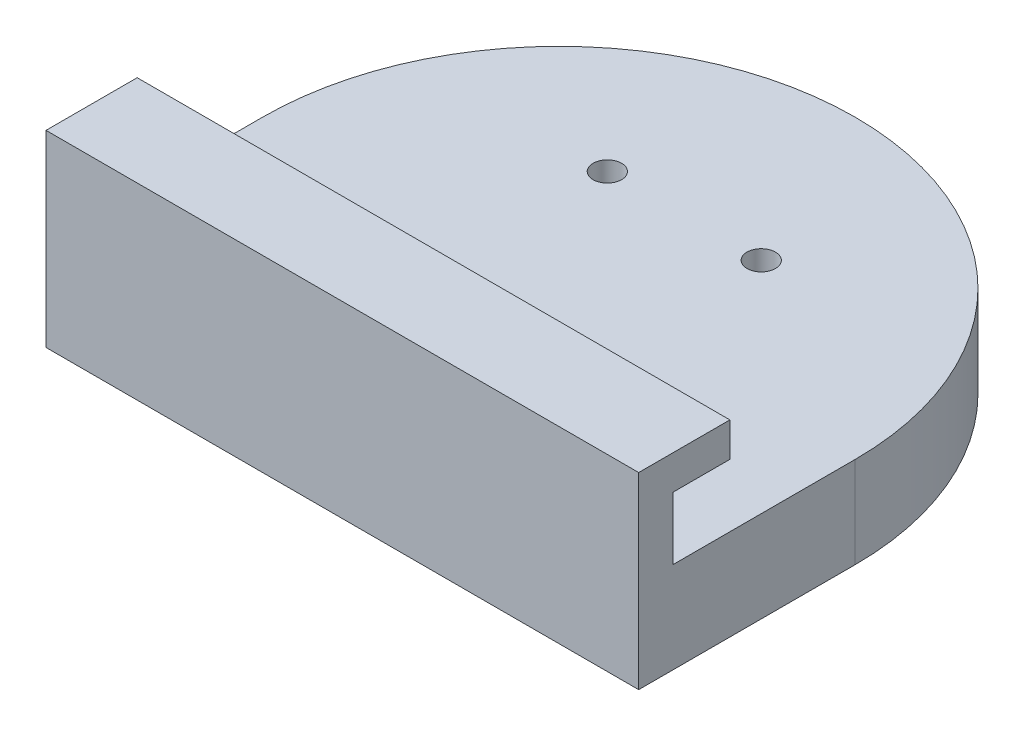
from build123d import *

# Parameters (mm, degrees)
BOSS_EXTRUDE1_DEPTH             = 2
BOSS_EXTRUDE3_DEPTH             = 8
BOSS_EXTRUDE2_REACH             = 28
BOSS_EXTRUDE2_DIRECTION_2_REACH = 28
TAP_DRILL_FOR_M3X0_5_TAP1_D     = 2.5
TAP_DRILL_FOR_M3X0_5_TAP1_DEPTH = 8


with BuildPart() as part:
    # Sketch1 → Boss-Extrude1 (new body)
    with BuildSketch(Plane(origin=(0, 0, 0), x_dir=(1, 0, 0), z_dir=(0, 1, 0))):
        with BuildLine():
            Line((-26, 0), (-26, -19))
            Line((-26, -19), (26, -19))
            Line((26, -19), (26, 0))
            ThreePointArc((26, 0), (0, 26), (-26, 0))
        make_face()
    extrude(amount=BOSS_EXTRUDE1_DEPTH)

    # Sketch1_3 → Boss-Extrude3 (add)
    with BuildSketch(Plane(origin=(0, 0, 0), x_dir=(1, 0, 0), z_dir=(0, 1, 0))):
        with BuildLine():
            ThreePointArc((26, 0), (0, 26), (-26, 0))
            Line((-26, 0), (-26, -19))
            Line((-26, -19), (26, -19))
            Line((26, -19), (26, 0))
        make_face()
    extrude(amount=BOSS_EXTRUDE3_DEPTH)

    # Boss-Extrude2: up to this face of the body (flat: up to its plane)
    boss_extrude2_end = Plane(part.part.faces().sort_by_distance((26, 4, 9.5))[0])
    # Sketch3 → Boss-Extrude2 (add, up to the picked face)
    with BuildSketch(Plane(origin=(0, 0, 0), x_dir=(0, 0, -1), z_dir=(1, 0, 0)), mode=Mode.PRIVATE) as boss_extrude2_sk1:
        Polygon((-19, 8), (-19, 16.5), (-11, 16.5), (-11, 13.5), (-16, 13.5), (-16, 8), align=None)
    boss_extrude2_tool1 = split(extrude(boss_extrude2_sk1.sketch, amount=BOSS_EXTRUDE2_REACH, mode=Mode.PRIVATE), bisect_by=boss_extrude2_end, keep=Keep.BOTH, mode=Mode.PRIVATE)
    add(boss_extrude2_tool1.solids().sort_by_distance((0, 13.268519, 16.018519))[0])

    # Boss-Extrude2 direction 2: up to this face of the body (flat: up to its plane)
    boss_extrude2_direction_2_end = Plane(part.part.faces().sort_by_distance((-26, 4, 9.5))[0])
    # Sketch3 → Boss-Extrude2 direction 2 (add, up to the picked face)
    with BuildSketch(Plane(origin=(0, 0, 0), x_dir=(0, 0, -1), z_dir=(1, 0, 0)), mode=Mode.PRIVATE) as boss_extrude2_direction_2_sk1:
        Polygon((-19, 8), (-19, 16.5), (-11, 16.5), (-11, 13.5), (-16, 13.5), (-16, 8), align=None)
    boss_extrude2_direction_2_tool1 = split(extrude(boss_extrude2_direction_2_sk1.sketch, amount=-BOSS_EXTRUDE2_DIRECTION_2_REACH, mode=Mode.PRIVATE), bisect_by=boss_extrude2_direction_2_end, keep=Keep.BOTH, mode=Mode.PRIVATE)
    add(boss_extrude2_direction_2_tool1.solids().sort_by_distance((0, 13.268519, 16.018519))[0])

    # Tap Drill for M3x0.5 Tap1
    with Locations(Plane(origin=(0, 0, 0), x_dir=(-1, 0, 0), z_dir=(0, -1, 0))):
        with Locations((-6.75, 11), (6.75, 11), (6.75, -11), (-6.75, -11)):
            Hole(TAP_DRILL_FOR_M3X0_5_TAP1_D / 2, depth=TAP_DRILL_FOR_M3X0_5_TAP1_DEPTH)


solid = part.part
